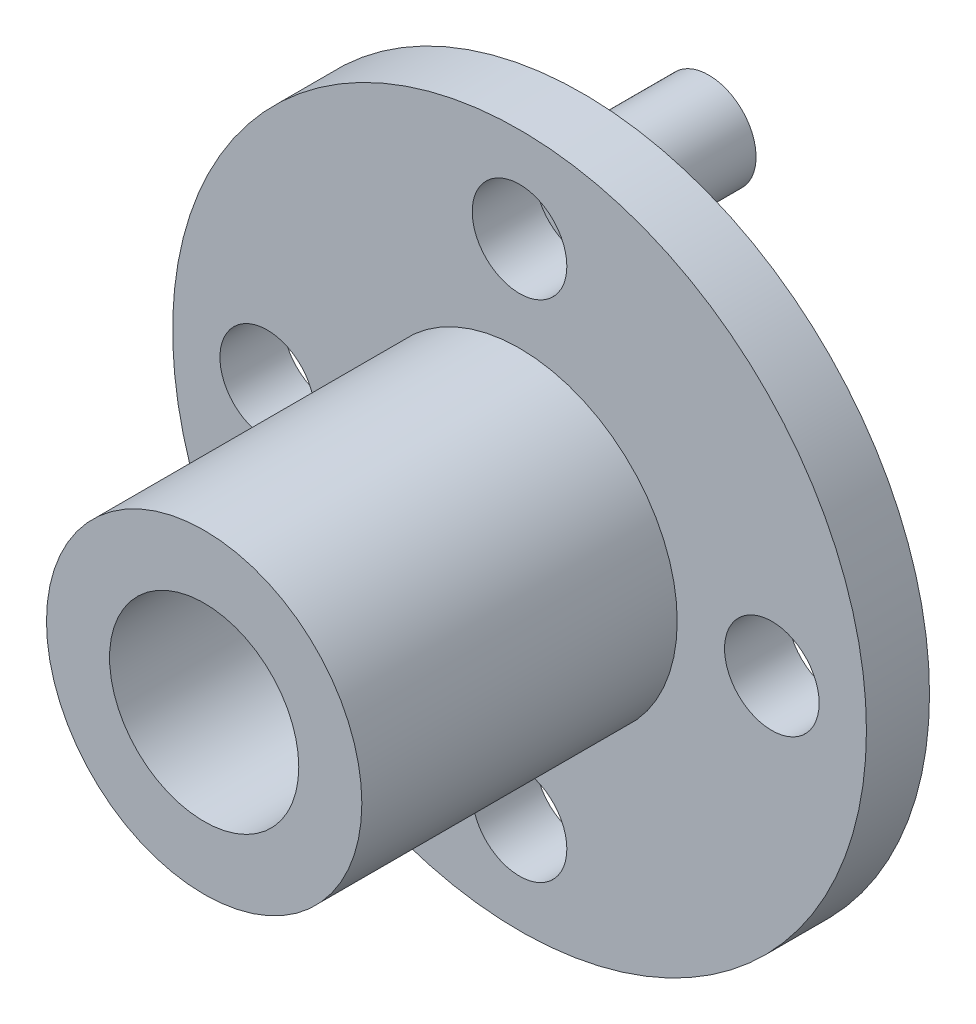
from build123d import *

# Parameters (mm, degrees)
SKETCH_1_R          = 11
EXTRUDE_1_DEPTH     = 2
SKETCH_2_R          = 5
EXTRUDE_2_DEPTH     = 10
SKETCH_4_R          = 3
CUT_EXTRUDE_2_DEPTH = 13
CUT_EXTRUDE_3_REACH = 4
SKETCH_5_R          = 1.5
SKETCH_6_R          = 1.5
EXTRUDE_3_DEPTH     = 4


with BuildPart() as part:
    # 草图1 → 凸台-拉伸1 (new body)
    with BuildSketch(Plane.XY):
        Circle(SKETCH_1_R)
    extrude(amount=EXTRUDE_1_DEPTH)

    # 草图2 → 凸台-拉伸2 (add)
    with BuildSketch(Plane.XY.offset(2)):
        Circle(SKETCH_2_R)
    extrude(amount=EXTRUDE_2_DEPTH)

    # 草图4 → 切除-拉伸2 (cut, through all)
    with BuildSketch(Plane.XY.offset(12)):
        Circle(SKETCH_4_R)
    extrude(amount=-CUT_EXTRUDE_2_DEPTH, mode=Mode.SUBTRACT)

    # 草图5 → 切除-拉伸3 (cut, up to next)
    with BuildSketch(Plane.XY.offset(2), mode=Mode.PRIVATE) as cut_extrude_3_sk1:
        with Locations((-8, 0)):
            Circle(SKETCH_5_R)
    cut_extrude_3_tool1 = extrude(cut_extrude_3_sk1.sketch, amount=-CUT_EXTRUDE_3_REACH, mode=Mode.PRIVATE) & part.part
    add(cut_extrude_3_tool1.solids().sort_by_distance((-8, 0, 2))[0], mode=Mode.SUBTRACT)
    # 草图5 → 切除-拉伸3 (cut, up to next)
    with BuildSketch(Plane.XY.offset(2), mode=Mode.PRIVATE) as cut_extrude_3_sk2:
        with Locations((0, 8)):
            Circle(SKETCH_5_R)
    cut_extrude_3_tool2 = extrude(cut_extrude_3_sk2.sketch, amount=-CUT_EXTRUDE_3_REACH, mode=Mode.PRIVATE) & part.part
    add(cut_extrude_3_tool2.solids().sort_by_distance((0, 8, 2))[0], mode=Mode.SUBTRACT)
    # 草图5 → 切除-拉伸3 (cut, up to next)
    with BuildSketch(Plane.XY.offset(2), mode=Mode.PRIVATE) as cut_extrude_3_sk3:
        with Locations((8, 0)):
            Circle(SKETCH_5_R)
    cut_extrude_3_tool3 = extrude(cut_extrude_3_sk3.sketch, amount=-CUT_EXTRUDE_3_REACH, mode=Mode.PRIVATE) & part.part
    add(cut_extrude_3_tool3.solids().sort_by_distance((8, 0, 2))[0], mode=Mode.SUBTRACT)
    # 草图5 → 切除-拉伸3 (cut, up to next)
    with BuildSketch(Plane.XY.offset(2), mode=Mode.PRIVATE) as cut_extrude_3_sk4:
        with Locations((0, -8)):
            Circle(SKETCH_5_R)
    cut_extrude_3_tool4 = extrude(cut_extrude_3_sk4.sketch, amount=-CUT_EXTRUDE_3_REACH, mode=Mode.PRIVATE) & part.part
    add(cut_extrude_3_tool4.solids().sort_by_distance((0, -8, 2))[0], mode=Mode.SUBTRACT)


with BuildPart() as body_2:
    # 草图6 → 凸台-拉伸3 (new body)
    with BuildSketch(Plane(origin=(0, 0, 0), x_dir=(-1, 0, 0), z_dir=(0, 0, -1))):
        with Locations((0, 8)):
            Circle(SKETCH_6_R)
    extrude(amount=EXTRUDE_3_DEPTH)


solid = Compound([part.part, body_2.part])
